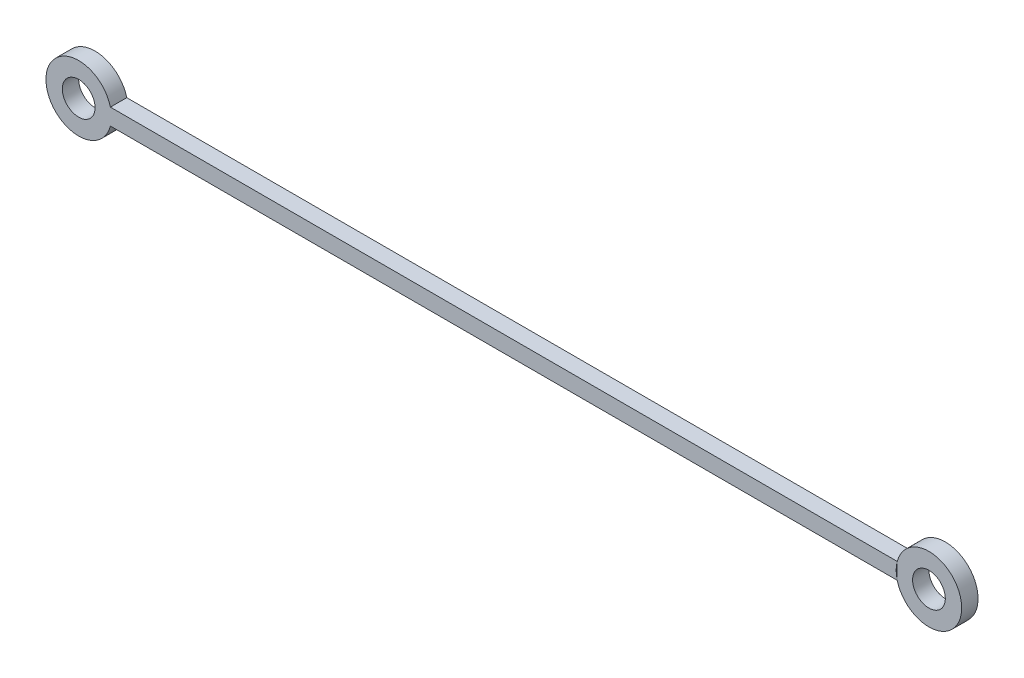
from build123d import *

# Parameters (mm, degrees)
SKETCH2_R           = 2
BOSS_EXTRUDE1_DEPTH = 2


with BuildPart() as part:
    # Sketch2 → Boss-Extrude1 (new body)
    with BuildSketch(Plane.XY):
        with BuildLine():
            ThreePointArc((-99.872983346, 0), (-99.904864561, 0.50401717), (-100, 1))
            Line((-100, 1), (-102.140932539, 1))
            ThreePointArc((-102.140932539, 1), (-101.941131694, 0.51763809), (-101.872983346, 0))
            ThreePointArc((-101.872983346, 0), (-101.941131694, -0.51763809), (-102.140932539, -1))
            Line((-102.140932539, -1), (-100, -1))
            ThreePointArc((-100, -1), (-99.904864561, -0.50401717), (-99.872983346, 0))
        make_face()
        with BuildLine():
            Line((-102.140932539, 1), (-100, 1))
            ThreePointArc((-100, 1), (-107.872983346, 0), (-100, -1))
            Line((-100, -1), (-102.140932539, -1))
            ThreePointArc((-102.140932539, -1), (-105.872983346, 0), (-102.140932539, 1))
        make_face()
        with BuildLine():
            ThreePointArc((-3.872983346, -1), (-4, 0), (-3.872983346, 1))
            Line((-3.872983346, 1), (-100, 1))
            ThreePointArc((-100, 1), (-99.904864561, 0.50401717), (-99.872983346, 0))
            ThreePointArc((-99.872983346, 0), (-99.904864561, -0.50401717), (-100, -1))
            Line((-100, -1), (-3.872983346, -1))
        make_face()
        with BuildLine():
            ThreePointArc((4, 0), (0.50401717, 3.968118785), (-3.872983346, 1))
            Line((-3.872983346, 1), (-3.872983346, -1))
            ThreePointArc((-3.872983346, -1), (0.50401717, -3.968118785), (4, 0))
        make_face()
        Circle(SKETCH2_R, mode=Mode.SUBTRACT)
    extrude(amount=BOSS_EXTRUDE1_DEPTH)


solid = part.part
